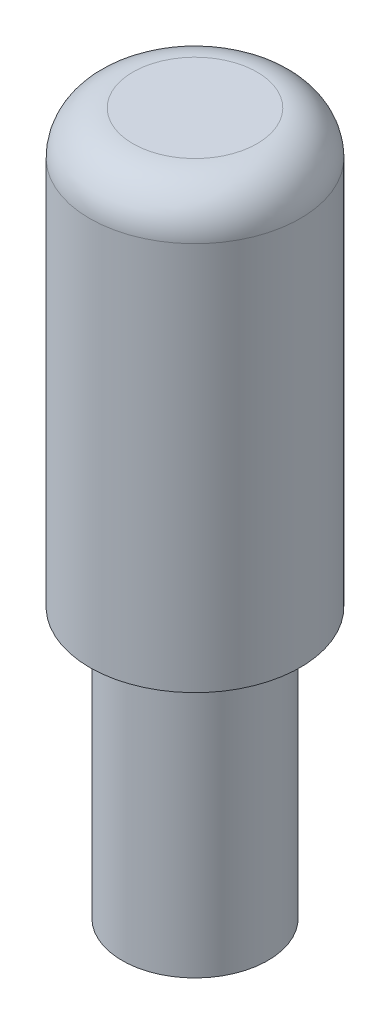
from build123d import *

# Parameters (mm, degrees)
SKETCH1_R           = 97.5
BOSS_EXTRUDE1_DEPTH = 650
SKETCH2_R           = 97.5
SKETCH2_R_2         = 67.5
CUT_EXTRUDE4_DEPTH  = 250
SKETCH4_R           = 67.5
CUT_EXTRUDE3_DEPTH  = 98.5
FILLET1_R           = 40


with BuildPart() as part:
    # Sketch1 → Boss-Extrude1 (new body)
    with BuildSketch(Plane(origin=(0, 0, 0), x_dir=(1, 0, 0), z_dir=(0, 1, 0))):
        Circle(SKETCH1_R)
    extrude(amount=BOSS_EXTRUDE1_DEPTH)

    # Sketch2 → Cut-Extrude4 (cut)
    with BuildSketch(Plane.XZ):
        Circle(SKETCH2_R)
        Circle(SKETCH2_R_2, mode=Mode.SUBTRACT)
    extrude(amount=-CUT_EXTRUDE4_DEPTH, mode=Mode.SUBTRACT)

    # Sketch4 → Cut-Extrude3 (cut, through all)
    with BuildSketch(Plane.XY):
        with Locations((0, 450)):
            Circle(SKETCH4_R)
    extrude(amount=-CUT_EXTRUDE3_DEPTH, mode=Mode.SUBTRACT)

    # Fillet1
    fillet1_edges = [part.edges().sort_by_distance(p)[0] for p in [
        (-97.5, 650, 0),
    ]]
    fillet(fillet1_edges, radius=FILLET1_R)


solid = part.part
